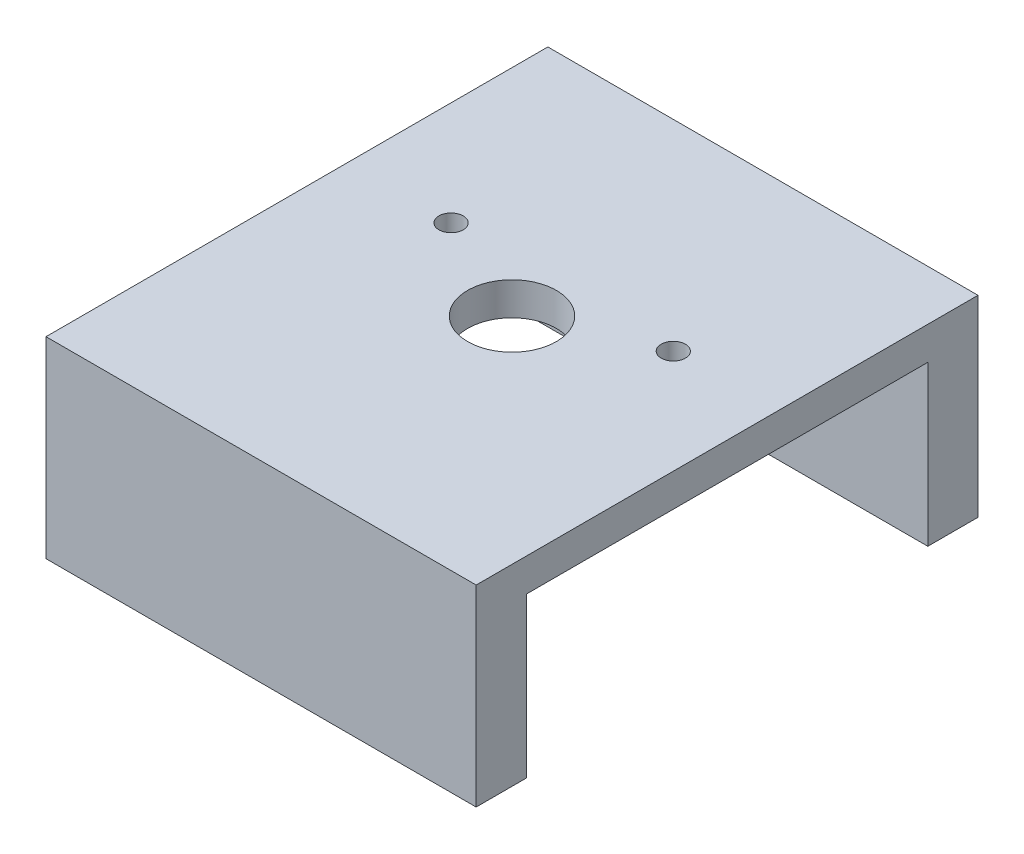
from build123d import *

# Parameters (mm, degrees)
SKETCH2_W                      = 60
SKETCH2_H                      = 70
BOSS_EXTRUDE1_DEPTH            = 4.5974
SKETCH4_R                      = 6.1905
SKETCH4_R_2                    = 1.6905
CUT_EXTRUDE1_DEPTH             = 93.309999928
SKETCH5_W                      = 60
SKETCH5_H                      = 22.225
BOSS_EXTRUDE2_DEPTH            = 7
F_6_32_TAPPED_HOLE1_AT_2_COUNT = 2
F_6_32_TAPPED_HOLE1_AT_2_PITCH = 47.298975859


with BuildPart() as part:
    # Sketch2 → Boss-Extrude1 (new body)
    with BuildSketch(Plane(origin=(0, 0, 0), x_dir=(1, 0, 0), z_dir=(0, 1, 0))):
        with Locations((30, 35)):
            Rectangle(SKETCH2_W, SKETCH2_H)
    extrude(amount=BOSS_EXTRUDE1_DEPTH)

    # Sketch4 → Cut-Extrude1 (cut, through all)
    with BuildSketch(Plane(origin=(0, 4.5974, 0), x_dir=(1, 0, 0), z_dir=(0, 1, 0))):
        with Locations(Location((30, 35, 0), (0, 0, 270))):
            Circle(SKETCH4_R)
        with Locations(Location((45.5, 42, 0), (0, 0, 270))):
            Circle(SKETCH4_R_2)
        with Locations(Location((14.5, 42, 0), (0, 0, 270))):
            Circle(SKETCH4_R_2)
    extrude(amount=-CUT_EXTRUDE1_DEPTH, mode=Mode.SUBTRACT)

    # Sketch5 → Boss-Extrude2 (add)
    with BuildSketch(Plane(origin=(0, 0, -70), x_dir=(-1, 0, 0), z_dir=(0, 0, -1))):
        with Locations((-30, -11.1125)):
            Rectangle(SKETCH5_W, SKETCH5_H)
    boss_extrude2 = extrude(amount=-BOSS_EXTRUDE2_DEPTH)

    # Sketch8 → #6-32 Tapped Hole1 (revolve, cut)
    with BuildSketch(Plane(origin=(6.35104386, -22.225, -66.368109228), x_dir=(0, 0, -1), z_dir=(1, 0, 0))):
        Polygon((0, 0), (0, 26.21269403), (1.35255, 25.4), (1.35255, 0), align=None)
    f_6_32_tapped_hole1 = revolve(axis=Axis((6.35104386, -28.575, -66.368109228), (0, 1, 0)), mode=Mode.SUBTRACT)

    # #6-32 Tapped Hole1 at 2: #6-32 Tapped Hole1 ×2
    with Locations(*[Vector(0.9999995830982151, 0, 0.0009131283567521887) * (i * F_6_32_TAPPED_HOLE1_AT_2_PITCH) for i in range(1, F_6_32_TAPPED_HOLE1_AT_2_COUNT)]):
        add(f_6_32_tapped_hole1, mode=Mode.SUBTRACT)

    # Mirror1: Boss-Extrude2, #6-32 Tapped Hole1 across plane
    add(boss_extrude2.mirror(Plane(origin=(0, 0, -35), x_dir=(1, 0, 0), z_dir=(0, 0, -1))))
    add(f_6_32_tapped_hole1.mirror(Plane(origin=(0, 0, -35), x_dir=(1, 0, 0), z_dir=(0, 0, -1))), mode=Mode.SUBTRACT)

    # Mirror1 copy 1 sketch → Mirror1 copy 1 (revolve, cut)
    with BuildSketch(Plane(origin=(53.65, -22.225, -3.675080808), x_dir=(0, 0, 1), z_dir=(1, 0, 0))):
        Polygon((0, 0), (0, -26.21269403), (1.35255, -25.4), (1.35255, 0), align=None)
    revolve(axis=Axis((53.65, -28.575, -3.675080808), (0, -1, 0)), mode=Mode.SUBTRACT)


solid = part.part
